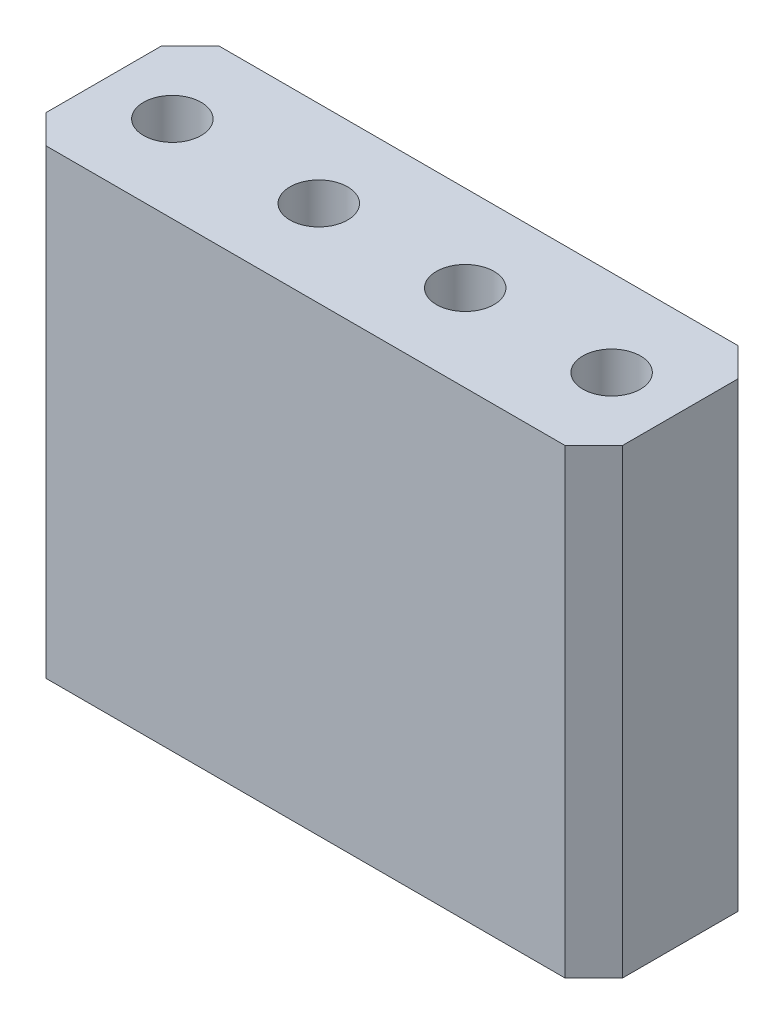
from build123d import *

# Parameters (mm, degrees)
SKETCH_1_W      = 10
SKETCH_1_H      = 3
SKETCH_1_W_2    = 0.64
SKETCH_1_H_2    = 0.64
EXTRUDE_1_DEPTH = 6
SKETCH_2_W      = 10
SKETCH_2_H      = 3
SKETCH_2_R      = 0.5
EXTRUDE_2_DEPTH = 2
CHAMFER_1_SIZE  = 0.5


with BuildPart() as part:
    # Эскиз1 → Бобышка-Вытянуть1 (new body)
    with BuildSketch(Plane(origin=(0, 0, 0), x_dir=(1, 0, 0), z_dir=(0, 1, 0))):
        Rectangle(SKETCH_1_W, SKETCH_1_H)
        with Locations((-3.81, 0)):
            Rectangle(SKETCH_1_W_2, SKETCH_1_H_2, mode=Mode.SUBTRACT)
        with Locations((3.81, 0)):
            Rectangle(SKETCH_1_W_2, SKETCH_1_H_2, mode=Mode.SUBTRACT)
        with Locations((-1.27, 0)):
            Rectangle(SKETCH_1_W_2, SKETCH_1_H_2, mode=Mode.SUBTRACT)
        with Locations((1.27, 0)):
            Rectangle(SKETCH_1_W_2, SKETCH_1_H_2, mode=Mode.SUBTRACT)
    extrude(amount=EXTRUDE_1_DEPTH)

    # Эскиз2 → Бобышка-Вытянуть2 (add)
    with BuildSketch(Plane(origin=(0, 6, 0), x_dir=(1, 0, 0), z_dir=(0, 1, 0))):
        Rectangle(SKETCH_2_W, SKETCH_2_H)
        with Locations((-3.81, 0)):
            Circle(SKETCH_2_R, mode=Mode.SUBTRACT)
        with Locations((-1.27, 0)):
            Circle(SKETCH_2_R, mode=Mode.SUBTRACT)
        with Locations((1.27, 0)):
            Circle(SKETCH_2_R, mode=Mode.SUBTRACT)
        with Locations((3.81, 0)):
            Circle(SKETCH_2_R, mode=Mode.SUBTRACT)
    extrude(amount=EXTRUDE_2_DEPTH)

    # Фаска1
    chamfer_1_edges = [part.edges().sort_by_distance(p)[0] for p in [
        (5, 4, 1.5),
        (-5, 4, 1.5),
        (-5, 4, -1.5),
        (5, 4, -1.5),
    ]]
    chamfer(chamfer_1_edges, length=CHAMFER_1_SIZE)


solid = part.part
